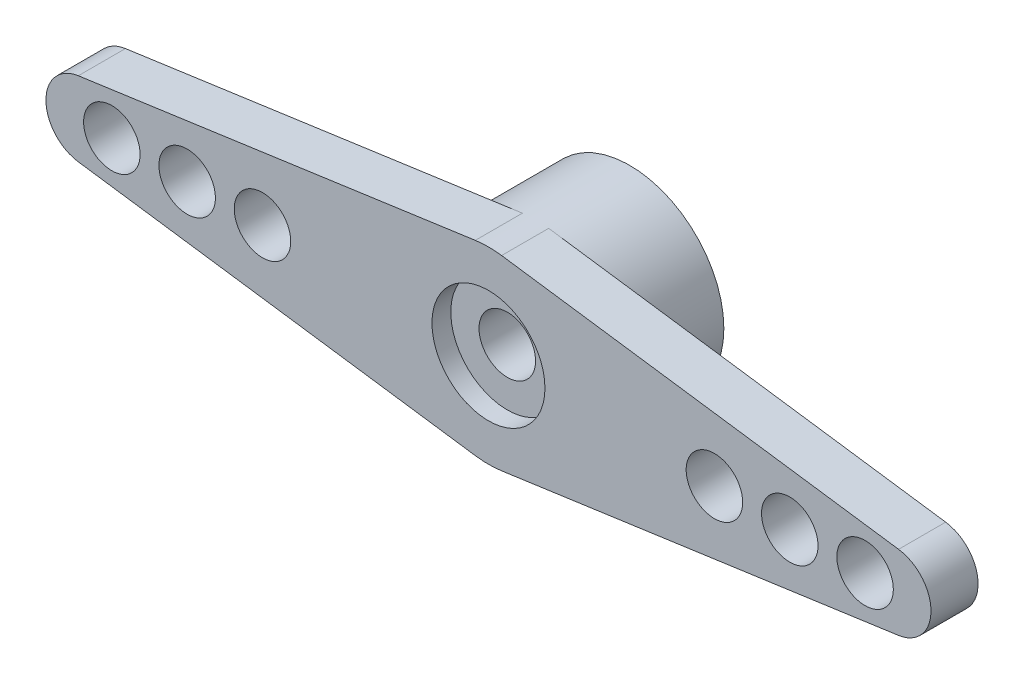
from build123d import *

# Parameters (mm, degrees)
EXTRUDE_2_DEPTH     = 2.5
CUT_EXTRUDE_1_REACH = 4.5
SKETCH_3_R          = 1.5
SKETCH_5_R          = 5
EXTRUDE_3_DEPTH     = 7.5
SKETCH_6_R          = 3
CUT_EXTRUDE_2_DEPTH = 3.4
SKETCH_7_R          = 1.5
CUT_EXTRUDE_3_DEPTH = 5.1
SKETCH_8_R          = 3
CUT_EXTRUDE_4_DEPTH = 1


with BuildPart() as part:
    # 草图1 → 凸台-拉伸2 (new body)
    with BuildSketch(Plane.XY):
        with BuildLine():
            Line((-21.779069767, 1.980434312), (-0.697674419, 4.95108578))
            ThreePointArc((-0.697674419, 4.95108578), (0, 5), (0.697674419, 4.95108578))
            Line((0.697674419, 4.95108578), (21.779069767, 1.980434312))
            ThreePointArc((21.779069767, 1.980434312), (23.5, 0), (21.779069767, -1.980434312))
            Line((21.779069767, -1.980434312), (0.697674419, -4.95108578))
            ThreePointArc((0.697674419, -4.95108578), (0, -5), (-0.697674419, -4.95108578))
            Line((-0.697674419, -4.95108578), (-21.779069767, -1.980434312))
            ThreePointArc((-21.779069767, -1.980434312), (-23.5, 0), (-21.779069767, 1.980434312))
        make_face()
    extrude(amount=EXTRUDE_2_DEPTH)

    # 草图3 → 切除-拉伸1 (cut, up to next)
    with BuildSketch(Plane.XY.offset(2.5), mode=Mode.PRIVATE) as cut_extrude_1_sk1:
        with Locations((-12, 0)):
            Circle(SKETCH_3_R)
    cut_extrude_1_tool1 = extrude(cut_extrude_1_sk1.sketch, amount=-CUT_EXTRUDE_1_REACH, mode=Mode.PRIVATE) & part.part
    add(cut_extrude_1_tool1.solids().sort_by_distance((-12, 0, 2.5))[0], mode=Mode.SUBTRACT)
    # 草图3 → 切除-拉伸1 (cut, up to next)
    with BuildSketch(Plane.XY.offset(2.5), mode=Mode.PRIVATE) as cut_extrude_1_sk2:
        with Locations((-16, 0)):
            Circle(SKETCH_3_R)
    cut_extrude_1_tool2 = extrude(cut_extrude_1_sk2.sketch, amount=-CUT_EXTRUDE_1_REACH, mode=Mode.PRIVATE) & part.part
    add(cut_extrude_1_tool2.solids().sort_by_distance((-16, 0, 2.5))[0], mode=Mode.SUBTRACT)
    # 草图3 → 切除-拉伸1 (cut, up to next)
    with BuildSketch(Plane.XY.offset(2.5), mode=Mode.PRIVATE) as cut_extrude_1_sk3:
        with Locations((-20, 0)):
            Circle(SKETCH_3_R)
    cut_extrude_1_tool3 = extrude(cut_extrude_1_sk3.sketch, amount=-CUT_EXTRUDE_1_REACH, mode=Mode.PRIVATE) & part.part
    add(cut_extrude_1_tool3.solids().sort_by_distance((-20, 0, 2.5))[0], mode=Mode.SUBTRACT)
    # 草图3 → 切除-拉伸1 (cut, up to next)
    with BuildSketch(Plane.XY.offset(2.5), mode=Mode.PRIVATE) as cut_extrude_1_sk4:
        with Locations((12, 0)):
            Circle(SKETCH_3_R)
    cut_extrude_1_tool4 = extrude(cut_extrude_1_sk4.sketch, amount=-CUT_EXTRUDE_1_REACH, mode=Mode.PRIVATE) & part.part
    add(cut_extrude_1_tool4.solids().sort_by_distance((12, 0, 2.5))[0], mode=Mode.SUBTRACT)
    # 草图3 → 切除-拉伸1 (cut, up to next)
    with BuildSketch(Plane.XY.offset(2.5), mode=Mode.PRIVATE) as cut_extrude_1_sk5:
        with Locations((16, 0)):
            Circle(SKETCH_3_R)
    cut_extrude_1_tool5 = extrude(cut_extrude_1_sk5.sketch, amount=-CUT_EXTRUDE_1_REACH, mode=Mode.PRIVATE) & part.part
    add(cut_extrude_1_tool5.solids().sort_by_distance((16, 0, 2.5))[0], mode=Mode.SUBTRACT)
    # 草图3 → 切除-拉伸1 (cut, up to next)
    with BuildSketch(Plane.XY.offset(2.5), mode=Mode.PRIVATE) as cut_extrude_1_sk6:
        with Locations((20, 0)):
            Circle(SKETCH_3_R)
    cut_extrude_1_tool6 = extrude(cut_extrude_1_sk6.sketch, amount=-CUT_EXTRUDE_1_REACH, mode=Mode.PRIVATE) & part.part
    add(cut_extrude_1_tool6.solids().sort_by_distance((20, 0, 2.5))[0], mode=Mode.SUBTRACT)

    # 草图5 → 凸台-拉伸3 (add)
    with BuildSketch(Plane.XY.offset(2.5)):
        Circle(SKETCH_5_R)
    extrude(amount=-EXTRUDE_3_DEPTH)

    # 草图6 → 切除-拉伸2 (cut)
    with BuildSketch(Plane(origin=(0, 0, -5), x_dir=(-1, 0, 0), z_dir=(0, 0, -1))):
        Circle(SKETCH_6_R)
    extrude(amount=-CUT_EXTRUDE_2_DEPTH, mode=Mode.SUBTRACT)

    # 草图7 → 切除-拉伸3 (cut, through all)
    with BuildSketch(Plane(origin=(0, 0, -1.6), x_dir=(-1, 0, 0), z_dir=(0, 0, -1))):
        Circle(SKETCH_7_R)
    extrude(amount=-CUT_EXTRUDE_3_DEPTH, mode=Mode.SUBTRACT)

    # 草图8 → 切除-拉伸4 (cut)
    with BuildSketch(Plane.XY.offset(2.5)):
        Circle(SKETCH_8_R)
    extrude(amount=-CUT_EXTRUDE_4_DEPTH, mode=Mode.SUBTRACT)


solid = part.part
